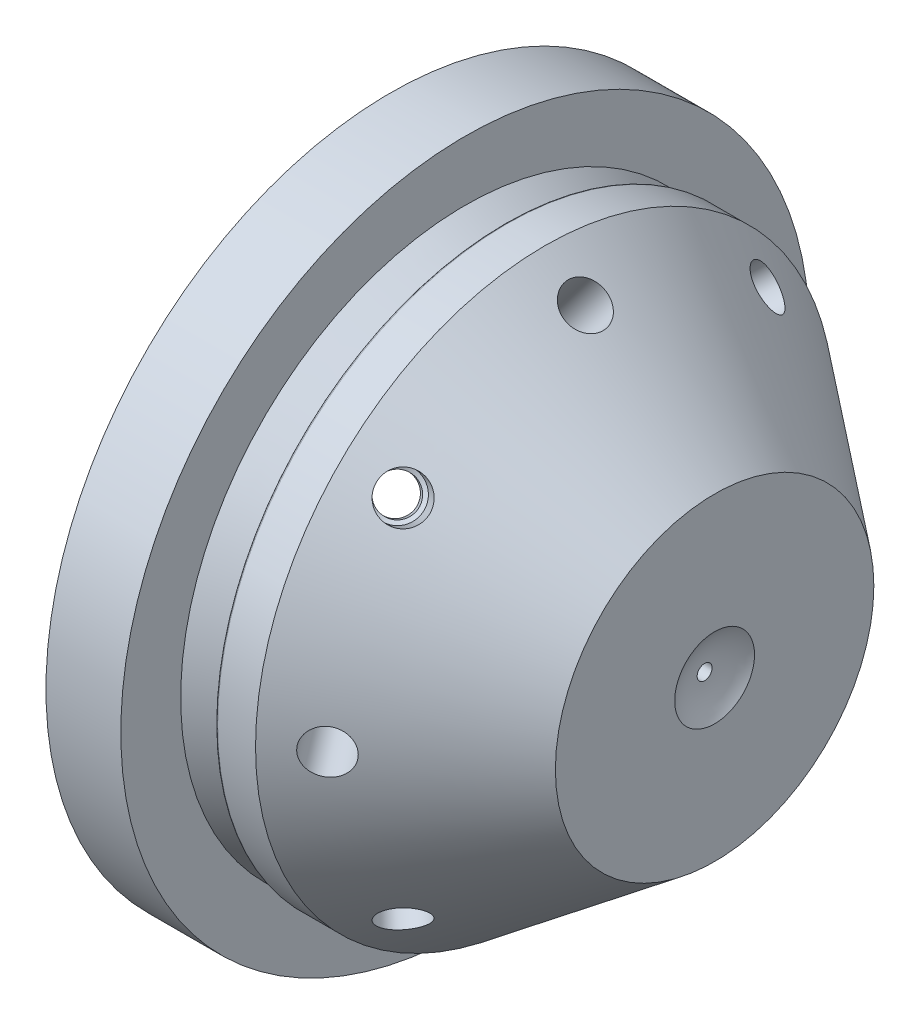
from build123d import *

# Parameters (mm, degrees)
F_8_X_BOHRUNG_2_2MM_COUNT             = 8
F_1_5_1_5_DURCHMESSER_BOHRUNG1_REACH  = 25.88
F_1_5_1_5_DURCHMESSER_BOHRUNG1_BORE_R = 0.75


with BuildPart() as part:
    # Teil → Rotation (revolve)
    with BuildSketch(Plane.XY, mode=Mode.PRIVATE) as rotation_sk:
        with BuildLine():
            Line((0, 2), (0, 7.977720602))
            Line((0, 7.977720602), (-8.5, 14.5))
            Line((-8.5, 14.5), (-10.4, 14.5))
            ThreePointArc((-10.4, 14.5), (-10.470710678, 14.470710678), (-10.5, 14.4))
            Line((-10.5, 14.4), (-10.5, 13.897213595))
            ThreePointArc((-10.5, 13.897213595), (-10.689707555, 13.556953272), (-11.078885438, 13.539442719))
            Line((-11.078885438, 13.539442719), (-12.5, 14.25))
            Line((-12.5, 14.25), (-12.5, 17.25))
            Line((-12.5, 17.25), (-16.25, 17.25))
            Line((-16.25, 17.25), (-16.25, 15.25))
            Line((-16.25, 15.25), (-15.087361614, 14.756170274))
            ThreePointArc((-15.087361614, 14.756170274), (-14.879716598, 14.553797352), (-14.863345797, 14.264309444))
            Line((-14.863345797, 14.264309444), (-16.25, 10))
            Line((-16.25, 10), (-16.25, 7.5))
            Line((-16.25, 7.5), (-12.75, 7.5))
            Line((-12.75, 7.5), (-10.5, 5.25))
            Line((-10.5, 5.25), (-8.25, 5.25))
            Line((-8.25, 5.25), (-5.657916521, 0.375))
            Line((-5.657916521, 0.375), (-0.5, 0.375))
            ThreePointArc((-0.5, 0.375), (-0.367525147, 1.223661584), (0, 2))
        make_face()
    revolve(rotation_sk.sketch.rotate(Axis((45.566038184, 0, 0), (-1, 0, 0)), 90), axis=Axis((45.566038184, 0, 0), (-1, 0, 0)))  # turned: the seam where the file's is

    # Bemaßung → Bohrung 2.2mm (revolve, cut)
    with BuildSketch(Plane(origin=(-6.460650242, 12.935151892, 4.13e-07), x_dir=(-0.493080912, 0.378354266, 0.783402364), z_dir=(0.621514872, -0.476905155, 0.621514872))):
        Polygon((0, 0), (0, 23.048147699), (0.9, 22.507373142), (0.9, 6.120172124), (1.1, 6), (1.1, 0), align=None)
    bohrung_2_2mm = revolve(axis=Axis((-2.728928133, 17.798426829, 5.68e-07), (-0.608761429, -0.79335334, -2.5e-08)), mode=Mode.SUBTRACT)

    # 8 x Bohrung 2.2mm: Bohrung 2.2mm ×8 about axis
    f_8_x_bohrung_2_2mm_axis = Axis((0, 0, 0), (-1, 0, 0))
    for i in range(1, F_8_X_BOHRUNG_2_2MM_COUNT):
        add(bohrung_2_2mm.rotate(f_8_x_bohrung_2_2mm_axis, i * 360 / F_8_X_BOHRUNG_2_2MM_COUNT), mode=Mode.SUBTRACT)

    # Ø1.5 (1.5) Durchmesser Bohrung1 bore (on position points) → Ø1.5 (1.5) Durchmesser Bohrung1 (cut, up to next)
    with BuildSketch(Plane(origin=(-15.626801071, 11.916493005, -5.5e-08), x_dir=(-0.30923808, -0.950984653, 0), z_dir=(-0.950984653, 0.30923808, -1e-09)), mode=Mode.PRIVATE) as f_1_5_1_5_durchmesser_bohrung1_sk1:
        Circle(F_1_5_1_5_DURCHMESSER_BOHRUNG1_BORE_R)
    f_1_5_1_5_durchmesser_bohrung1_tool1 = extrude(f_1_5_1_5_durchmesser_bohrung1_sk1.sketch, amount=-F_1_5_1_5_DURCHMESSER_BOHRUNG1_REACH, mode=Mode.PRIVATE) & part.part
    add(f_1_5_1_5_durchmesser_bohrung1_tool1.solids().sort_by_distance((-15.626801, 11.916493, 0))[0], mode=Mode.SUBTRACT)


solid = part.part
